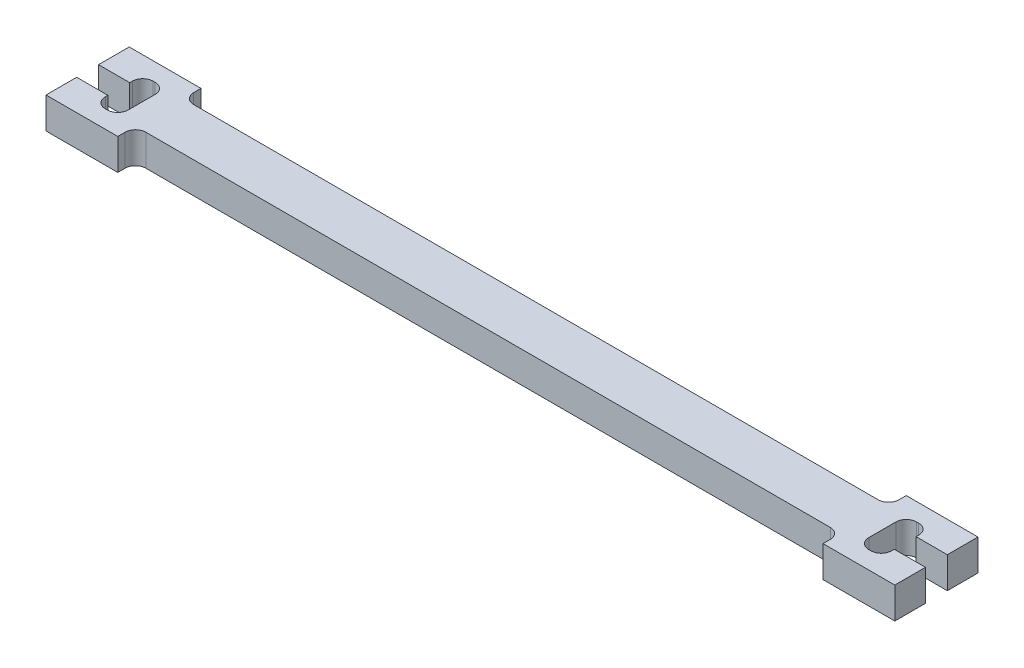
from build123d import *

# Parameters (mm, degrees)
BASE_SHAPE_DEPTH  = 3
MILLING_FILLETS_R = 1


with BuildPart() as part:
    # Sketch1 → Base shape (new body)
    with BuildSketch(Plane(origin=(0, 0, 0), x_dir=(1, 0, 0), z_dir=(0, 1, 0))):
        Polygon((-33.9, 4), (-40.8, 4), (-40.8, 1.05), (-37.8, 1.05), (-37.8, 2.3), (-35.6, 2.3), (-35.6, -2.3), (-37.8, -2.3), (-37.8, -1.05), (-40.8, -1.05), (-40.8, -4), (-33.9, -4), (-33.9, -2.3), (33.9, -2.3), (33.9, -4), (40.8, -4), (40.8, -1.05), (37.8, -1.05), (37.8, -2.3), (35.6, -2.3), (35.6, 2.3), (37.8, 2.3), (37.8, 1.05), (40.8, 1.05), (40.8, 4), (33.9, 4), (33.9, 2.3), (-33.9, 2.3), align=None)
    extrude(amount=BASE_SHAPE_DEPTH)

    # Milling fillets
    milling_fillets_edges = [part.edges().sort_by_distance(p)[0] for p in [
        (37.8, 1.5, 2.3),
        (-35.6, 1.5, 2.3),
        (-37.8, 1.5, 2.3),
        (35.6, 1.5, 2.3),
        (35.6, 1.5, -2.3),
        (-37.8, 1.5, -2.3),
        (-35.6, 1.5, -2.3),
        (37.8, 1.5, -2.3),
        (33.9, 1.5, 2.3),
        (33.9, 1.5, -2.3),
        (-33.9, 1.5, -2.3),
        (-33.9, 1.5, 2.3),
    ]]
    fillet(milling_fillets_edges, radius=MILLING_FILLETS_R)


solid = part.part
